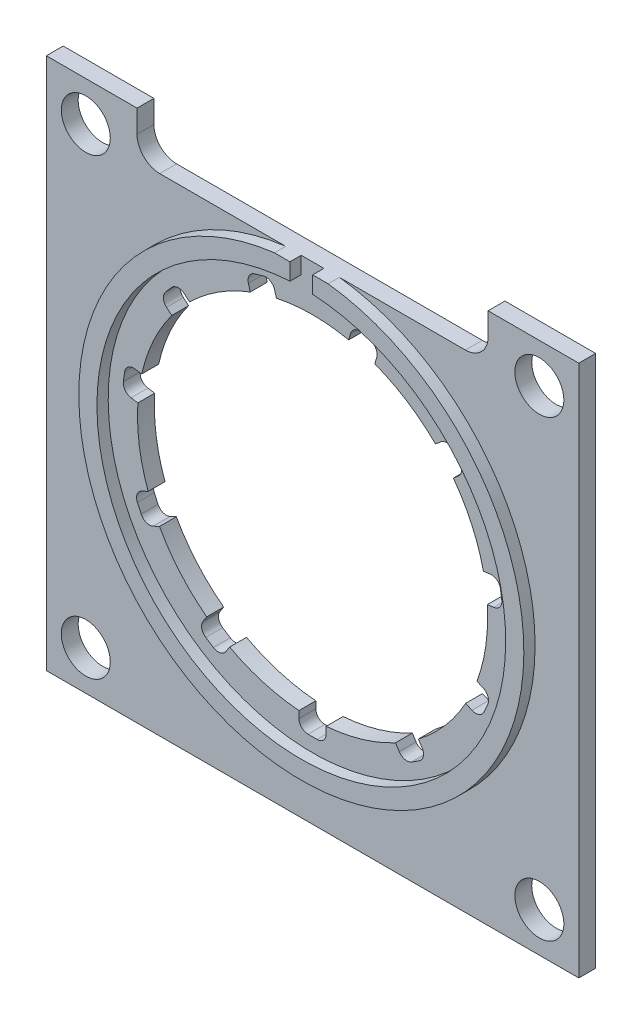
from build123d import *

# Parameters (mm, degrees)
BOSS_EXTRUDE1_DEPTH      = 1.5875
BOSS_EXTRUDE1_DEPTH_BACK = 1.5875
SKETCH1_W                = 74.549
SKETCH1_H                = 74.549
SKETCH1_R                = 24.511
SKETCH2_R                = 3.429
CUT_EXTRUDE1_DEPTH       = 53.809632885
MIRROR2_COPY_1_SKETCH_R  = 3.429
MIRROR2_COPY_1_DEPTH     = 53.809632885
MIRROR2_COPY_2_SKETCH_R  = 3.429
MIRROR2_COPY_2_DEPTH     = 53.809632885
SKETCH15_R               = 31.1531
SKETCH15_R_2             = 28.6131
BOSS_EXTRUDE11_DEPTH     = 1.5748
CUT_EXTRUDE6_DEPTH       = 53.809632885
CUT_EXTRUDE6_DEPTH_BACK  = 53.809632885
SKETCH14_W               = 49.149
SKETCH14_H               = 8.290530285
FILLET2_R                = 3.175
CUT_EXTRUDE8_REACH       = 54.81
SKETCH18_W               = 74.549
SKETCH18_H               = 74.549
CUT_EXTRUDE9_DEPTH       = 0.8128
SKETCH19_W               = 3.81
SKETCH19_H               = 6.35
CUT_EXTRUDE10_DEPTH      = 53.767003793
FILLET3_R                = 1.27
CIRPATTERN2_COUNT        = 11
FILLET3_OF_CIRPATTERN2_R = 1.27


with BuildPart() as part:
    # Sketch1 → Boss-Extrude1 (new, two sides: drawn at the far end of the back side and taken through both)
    with BuildSketch(Plane.XY.offset(-BOSS_EXTRUDE1_DEPTH_BACK)):
        Rectangle(SKETCH1_W, SKETCH1_H)
        Circle(SKETCH1_R, mode=Mode.SUBTRACT)
    extrude(amount=BOSS_EXTRUDE1_DEPTH + BOSS_EXTRUDE1_DEPTH_BACK)

    # Sketch2 → Cut-Extrude1 (cut, through all)
    with BuildSketch(Plane.XY.offset(1.5875)):
        with Locations((-31.75, 31.75)):
            Circle(SKETCH2_R)
    cut_extrude1 = extrude(amount=-CUT_EXTRUDE1_DEPTH, mode=Mode.SUBTRACT)

    # Mirror1: Cut-Extrude1 across plane
    add(cut_extrude1.mirror(Plane(origin=(0, 0, 0), x_dir=(0, 0, 1), z_dir=(1, 0, 0))), mode=Mode.SUBTRACT)

    # Mirror2 copy 1 sketch → Mirror2 copy 1 (cut, through all)
    with BuildSketch(Plane(origin=(0, 0, 1.5875), x_dir=(-1, 0, 0), z_dir=(0, 0, 1))):
        with Locations((-31.75, 31.75)):
            Circle(MIRROR2_COPY_1_SKETCH_R)
    extrude(amount=-MIRROR2_COPY_1_DEPTH, mode=Mode.SUBTRACT)

    # Mirror2 copy 2 sketch → Mirror2 copy 2 (cut, through all)
    with BuildSketch(Plane.XY.offset(1.5875)):
        with Locations((-31.75, -31.75)):
            Circle(MIRROR2_COPY_2_SKETCH_R)
    extrude(amount=-MIRROR2_COPY_2_DEPTH, mode=Mode.SUBTRACT)

    # Sketch15 → Boss-Extrude11 (add)
    with BuildSketch(Plane.XY.offset(1.5875)):
        Circle(SKETCH15_R)
        Circle(SKETCH15_R_2, mode=Mode.SUBTRACT)
    extrude(amount=BOSS_EXTRUDE11_DEPTH)

    # Sketch14 → Cut-Extrude6 (cut, two sides: drawn at the far end of the back side and taken through both)
    with BuildSketch(Plane.XY.offset(1.5875).offset(-CUT_EXTRUDE6_DEPTH_BACK)):
        with Locations((0, 35.069765143)):
            Rectangle(SKETCH14_W, SKETCH14_H)
    extrude(amount=CUT_EXTRUDE6_DEPTH + CUT_EXTRUDE6_DEPTH_BACK, mode=Mode.SUBTRACT)

    # Fillet2
    fillet2_edges = [part.edges().sort_by_distance(p)[0] for p in [
        (-24.5745, 30.9245, 0),
        (24.5745, 30.9245, 0),
    ]]
    fillet(fillet2_edges, radius=FILLET2_R)

    # Sketch17 → Cut-Extrude8 (cut, up to next)
    with BuildSketch(Plane.XY.offset(1.5875), mode=Mode.PRIVATE) as cut_extrude8_sk1:
        with BuildLine():
            Line((-1.5875, 24.754637718), (-1.5875, 33.858616052))
            ThreePointArc((-1.5875, 33.858616052), (0, 35.446116052), (1.5875, 33.858616052))
            Line((1.5875, 33.858616052), (1.5875, 24.754637718))
            ThreePointArc((1.5875, 24.754637718), (0, 23.167137718), (-1.5875, 24.754637718))
        make_face()
    cut_extrude8_tool1 = extrude(cut_extrude8_sk1.sketch, amount=CUT_EXTRUDE8_REACH, mode=Mode.PRIVATE) & part.part
    add(cut_extrude8_tool1.solids().sort_by_distance((0, 29.306627, 1.5875))[0], mode=Mode.SUBTRACT)

    # Sketch18 → Cut-Extrude9 (cut)
    with BuildSketch(Plane(origin=(0, 0, -1.5875), x_dir=(-1, 0, 0), z_dir=(0, 0, -1))):
        Rectangle(SKETCH18_W, SKETCH18_H)
    extrude(amount=-CUT_EXTRUDE9_DEPTH, mode=Mode.SUBTRACT)

    # Sketch19 → Cut-Extrude10 (cut, through all)
    with BuildSketch(Plane.XY.offset(1.5875)):
        with Locations((0, -23.495)):
            Rectangle(SKETCH19_W, SKETCH19_H)
    cut_extrude10 = extrude(amount=-CUT_EXTRUDE10_DEPTH, mode=Mode.SUBTRACT)

    # Fillet3
    fillet3_edges = [part.edges().sort_by_distance(p)[0] for p in [
        (1.905, -26.67, 0.4064),
        (-1.905, -26.67, 0.4064),
    ]]
    fillet(fillet3_edges, radius=FILLET3_R)

    # CirPattern2: Cut-Extrude10 ×11 about axis
    cirpattern2_axis = Axis((0, 0, -1.5875), (0, 0, 1))
    for i in range(1, CIRPATTERN2_COUNT):
        add(cut_extrude10.rotate(cirpattern2_axis, i * 360 / CIRPATTERN2_COUNT), mode=Mode.SUBTRACT)

    # Fillet3 of CirPattern2
    fillet3_of_cirpattern2_edges = [part.edges().sort_by_distance(p)[0] for p in [
        (16.021478582, -21.406310963, 0.4064),
        (12.816302621, -23.466152478, 0.4064),
        (25.051250916, -9.346269446, 0.4064),
        (23.468519716, -12.811967348, 0.4064),
        (26.127428088, 5.681146584, 0.4064),
        (26.669647622, 1.90992689, 0.4064),
        (18.90833145, 18.904838713, 0.4064),
        (21.403350846, 16.025432835, 0.4064),
        (5.685973176, 26.126378127, 0.4064),
        (9.341641406, 25.052977086, 0.4064),
        (-9.341641406, 25.052977086, 0.4064),
        (-5.685973176, 26.126378127, 0.4064),
        (-21.403350846, 16.025432835, 0.4064),
        (-18.90833145, 18.904838713, 0.4064),
        (-26.669647622, 1.90992689, 0.4064),
        (-26.127428088, 5.681146584, 0.4064),
        (-23.468519716, -12.811967348, 0.4064),
        (-25.051250916, -9.346269446, 0.4064),
        (-12.816302621, -23.466152478, 0.4064),
        (-16.021478582, -21.406310963, 0.4064),
    ]]
    fillet(fillet3_of_cirpattern2_edges, radius=FILLET3_OF_CIRPATTERN2_R)


solid = part.part
